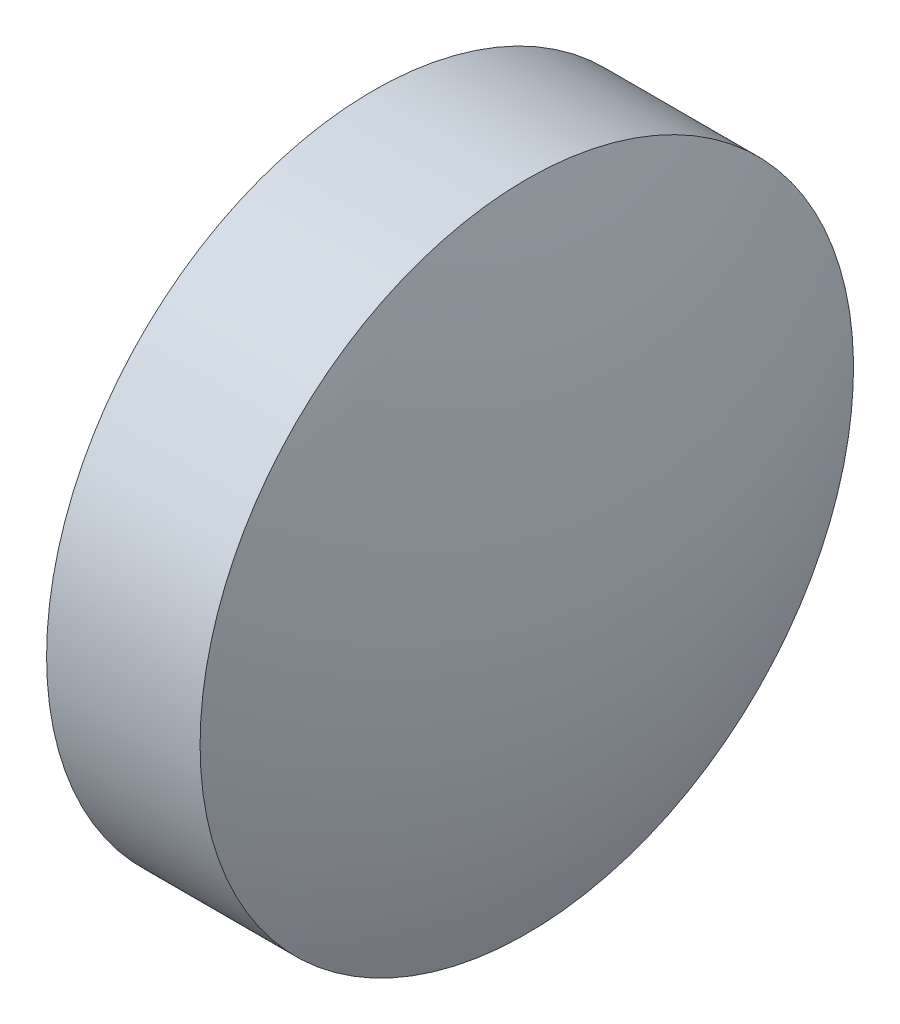
from build123d import *


with BuildPart() as part:
    # 草图2 → 旋转2 (revolve)
    with BuildSketch(Plane.XY):
        with BuildLine():
            Line((515.116275716, 138.924621118), (515.116275716, 142.074621118))
            Line((515.116275716, 142.074621118), (516.596275716, 142.074621118))
            ThreePointArc((516.596275716, 142.074621118), (517.059802925, 140.529839171), (517.216275716, 138.924621118))
            Line((517.216275716, 138.924621118), (515.116275716, 138.924621118))
        make_face()
    revolve(axis=Axis((514.626617733, 138.924621118, 0), (1, 0, 0)))


solid = part.part
